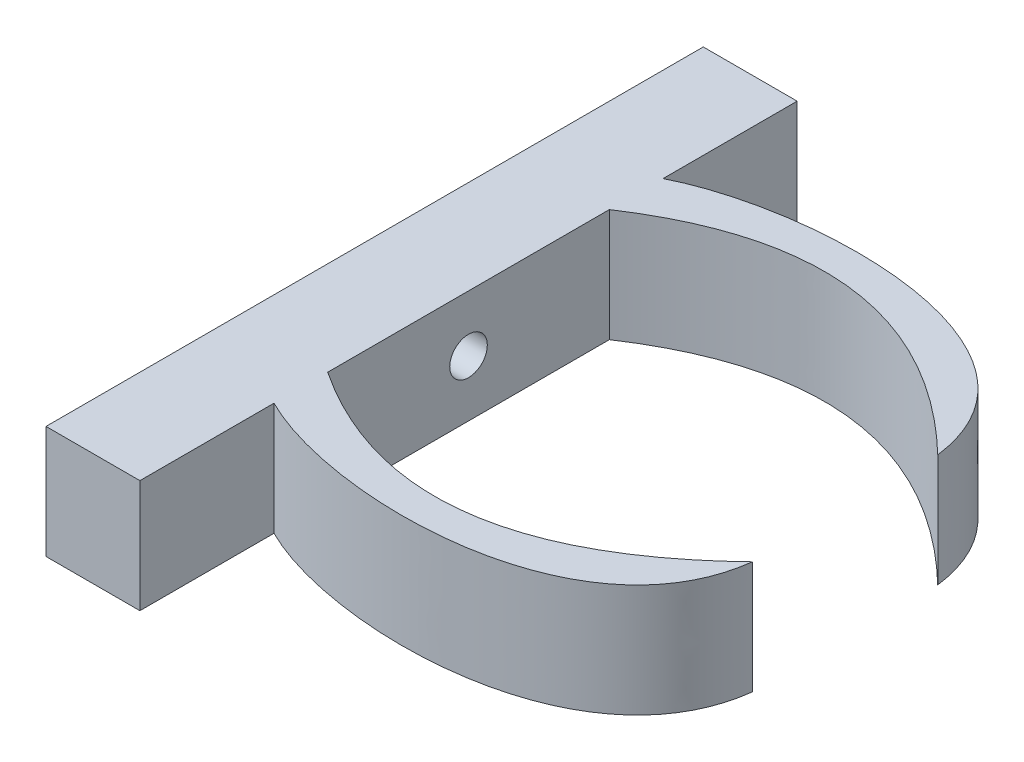
from build123d import *

# Parameters (mm, degrees)
SKETCH1_W           = 70
SKETCH1_H           = 12
BOSS_EXTRUDE1_DEPTH = 10
BOSS_EXTRUDE2_DEPTH = 12
SKETCH3_R           = 2
CUT_EXTRUDE1_DEPTH  = 12


with BuildPart() as part:
    # Sketch1 → Boss-Extrude1 (new body)
    with BuildSketch(Plane(origin=(0, 0, 0), x_dir=(0, 0, -1), z_dir=(1, 0, 0))):
        Rectangle(SKETCH1_W, SKETCH1_H)
    extrude(amount=BOSS_EXTRUDE1_DEPTH)

    # Sketch2 → Boss-Extrude2 (add)
    with BuildSketch(Plane(origin=(0, 6, 0), x_dir=(1, 0, 0), z_dir=(0, 1, 0))):
        with BuildLine():
            add(Edge.make_bspline(
                [(10, -15), (30.647953976, -28.668903478), (50.105658194, -9.868255971)],
                knots=[0, 0, 0, 1, 1, 1], degree=2))
            Line((10, -15), (10, -20.717636889))
            add(Edge.make_bspline(
                [(10, -20.717636889), (21.360270844, -26.451655212), (47.984708218, -26.799299217), (50.105658194, -9.868255971)],
                knots=[0, 0, 0, 0, 1, 1, 1, 1], degree=3))
        make_face()
        with BuildLine():
            Line((10, 20.717636889), (10, 15))
            add(Edge.make_bspline(
                [(10, 15), (30.647953976, 28.668903478), (50.105658194, 9.868255971)],
                knots=[0, 0, 0, 1, 1, 1], degree=2))
            add(Edge.make_bspline(
                [(10, 20.717636889), (21.360270844, 26.451655212), (47.984708218, 26.799299217), (50.105658194, 9.868255971)],
                knots=[0, 0, 0, 0, 1, 1, 1, 1], degree=3))
        make_face()
    extrude(amount=-BOSS_EXTRUDE2_DEPTH)

    # Sketch3 → Cut-Extrude1 (cut)
    with BuildSketch(Plane.ZY):
        Circle(SKETCH3_R)
    extrude(amount=-CUT_EXTRUDE1_DEPTH, mode=Mode.SUBTRACT)


solid = part.part
